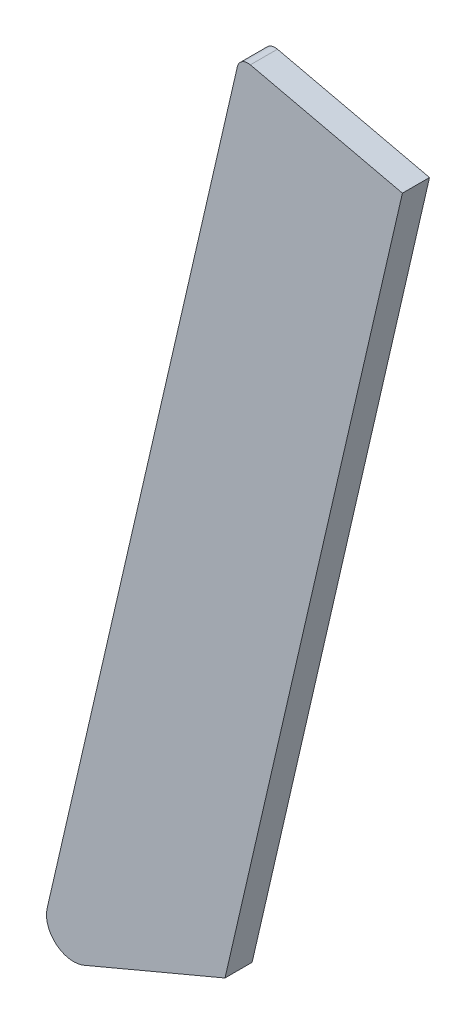
from build123d import *

# Parameters (mm, degrees)
BOSS_EXTRUDE1_DEPTH = 3.175


with BuildPart() as part:
    # Sketch1 → Boss-Extrude1 (new body)
    with BuildSketch(Plane.XY):
        with BuildLine():
            Line((-41.000315086, -26.287850411), (-63.287294611, -122.823364534))
            ThreePointArc((-63.287294611, -122.823364534), (-62.237386701, -125.967367174), (-58.959993868, -126.463104436))
            Line((-58.959993868, -126.463104436), (-42.447556795, -119.499900736))
            Line((-42.447556795, -119.499900736), (-21.65789752, -29.44999315))
            Line((-21.65789752, -29.44999315), (-39.477177265, -25.336088268))
            ThreePointArc((-39.477177265, -25.336088268), (-40.435862569, -25.496517168), (-41.000315086, -26.287850411))
        make_face()
    extrude(amount=BOSS_EXTRUDE1_DEPTH)


solid = part.part
